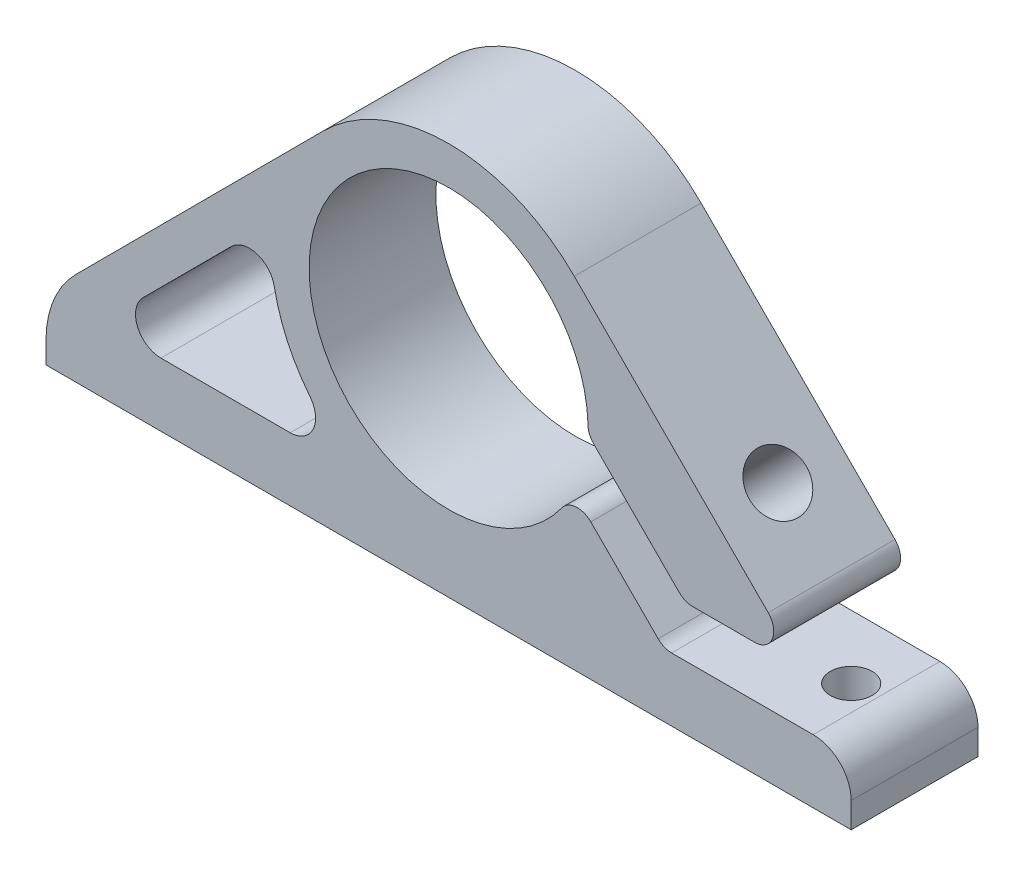
from build123d import *

# Parameters (mm, degrees)
SKETCH_1_R            = 11
EXTRUDE_1_DEPTH       = 10
CUT_EXTRUDE_1_DEPTH   = 11
FILLET_1_R            = 1.5
M4X0_71_D             = 3.3
M4X0_71_DEPTH         = 5
M4X0_71_TIP           = 0.991420021
HOLE_WIZARD_M41_D     = 4.5
HOLE_WIZARD_M41_DEPTH = 6.466619964
M4X0_72_D             = 3.3
FILLET_2_R            = 3
CUT_EXTRUDE_2_DEPTH   = 11
FILLET_3_R            = 2
FILLET_5_R            = 8


with BuildPart() as part:
    # Эскиз1 → Бобышка-Вытянуть1 (new body)
    with BuildSketch(Plane.XY):
        with BuildLine():
            Line((-31.75, -12), (-9.910576673, 9.888400781))
            ThreePointArc((-9.910576673, 9.888400781), (0, 14), (9.910576673, 9.888400781))
            Line((9.910576673, 9.888400781), (31.75, -12))
            Line((31.75, -12), (31.75, -17))
            Line((31.75, -17), (-31.75, -17))
            Line((-31.75, -17), (-31.75, -12))
        make_face()
        Circle(SKETCH_1_R, mode=Mode.SUBTRACT)
    extrude(amount=EXTRUDE_1_DEPTH)

    # Эскиз2 → Вырез-Вытянуть1 (cut, through all)
    with BuildSketch(Plane.XY.offset(10)):
        Polygon((10.994327356, -0.353222306), (18.623994631, -8), (31.75, -8), (31.75, -12), (16.964515327, -12), (9.858995646, -4.878545362), align=None)
    extrude(amount=-CUT_EXTRUDE_1_DEPTH, mode=Mode.SUBTRACT)

    # Скругление1
    fillet_1_edges = [part.edges().sort_by_distance(p)[0] for p in [
        (27.758950394, -8, 5),
        (18.623994631, -8, 5),
        (9.858995646, -4.878545362, 5),
        (10.994327356, -0.353222306, 5),
        (16.964515327, -12, 5),
    ]]
    fillet(fillet_1_edges, radius=FILLET_1_R)

    # Отверстие обработанное метчиком M4x0.71
    with Locations(Plane(origin=(0, -17, 0), x_dir=(-1, 0, 0), z_dir=(0, -1, 0))):
        with Locations((26.75, -5), (-26.75, -5)):
            Hole(M4X0_71_D / 2, depth=M4X0_71_DEPTH)
            with Locations((0, 0, -(M4X0_71_DEPTH + M4X0_71_TIP / 2))):  # 118° drill point
                Cone(0, M4X0_71_D / 2, M4X0_71_TIP, mode=Mode.SUBTRACT)

    # Отверстие с зазором M41
    with Locations(Plane(origin=(9.910576673, 9.888400781, 0), x_dir=(0, 0, -1), z_dir=(0.707898334, 0.706314342, 0))):
        with Locations((-5, -15.654139496)):
            Hole(HOLE_WIZARD_M41_D / 2, depth=HOLE_WIZARD_M41_DEPTH)

    # Отверстие обработанное метчиком M4x0.72 (through all)
    with Locations(Plane(origin=(2.50127384, 2.495676993, 0), x_dir=(0, 0, -1), z_dir=(0.707898334, 0.706314342, 0))):
        with Locations((-5, -15.654139496)):
            Hole(M4X0_72_D / 2)

    # Скругление2
    fillet_2_edges = [part.edges().sort_by_distance(p)[0] for p in [
        (31.75, -12, 5),
    ]]
    fillet(fillet_2_edges, radius=FILLET_2_R)

    # Эскиз11 → Вырез-Вытянуть2 (cut, through all)
    with BuildSketch(Plane.XY.offset(10)):
        with BuildLine():
            Line((-13.9037433, 1.638878353), (-24.107110728, -8.587371317))
            ThreePointArc((-24.107110728, -8.587371317), (-24.53864421, -10.766401538), (-22.69131406, -12))
            Line((-22.69131406, -12), (-7.211102551, -12))
            ThreePointArc((-7.211102551, -12), (-12.568370201, -6.167339012), (-13.9037433, 1.638878353))
        make_face()
    extrude(amount=-CUT_EXTRUDE_2_DEPTH, mode=Mode.SUBTRACT)

    # Скругление3
    fillet_3_edges = [part.edges().sort_by_distance(p)[0] for p in [
        (-13.9037433, 1.638878353, 5),
        (-7.211102551, -12, 5),
    ]]
    fillet(fillet_3_edges, radius=FILLET_3_R)

    # Скругление5
    fillet_5_edges = [part.edges().sort_by_distance(p)[0] for p in [
        (-31.75, -12, 5),
    ]]
    fillet(fillet_5_edges, radius=FILLET_5_R)


solid = part.part
